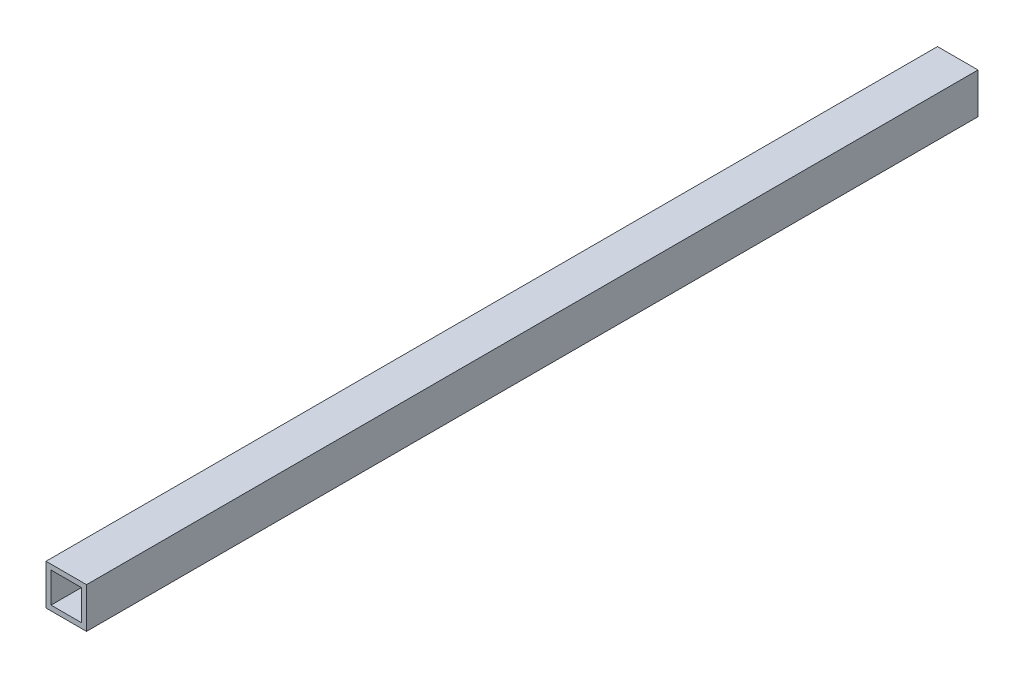
from build123d import *

# Parameters (mm, degrees)
SKETCH1_W           = 25.4
SKETCH1_H           = 25.4
SKETCH1_W_2         = 19.05
SKETCH1_H_2         = 19.05
BOSS_EXTRUDE1_DEPTH = 558.8


with BuildPart() as part:
    # Sketch1 → Boss-Extrude1 (new body)
    with BuildSketch(Plane.XY):
        with Locations((12.7, 12.7)):
            Rectangle(SKETCH1_W, SKETCH1_H)
        with Locations((12.7, 12.7)):
            Rectangle(SKETCH1_W_2, SKETCH1_H_2, mode=Mode.SUBTRACT)
    extrude(amount=BOSS_EXTRUDE1_DEPTH)


solid = part.part
